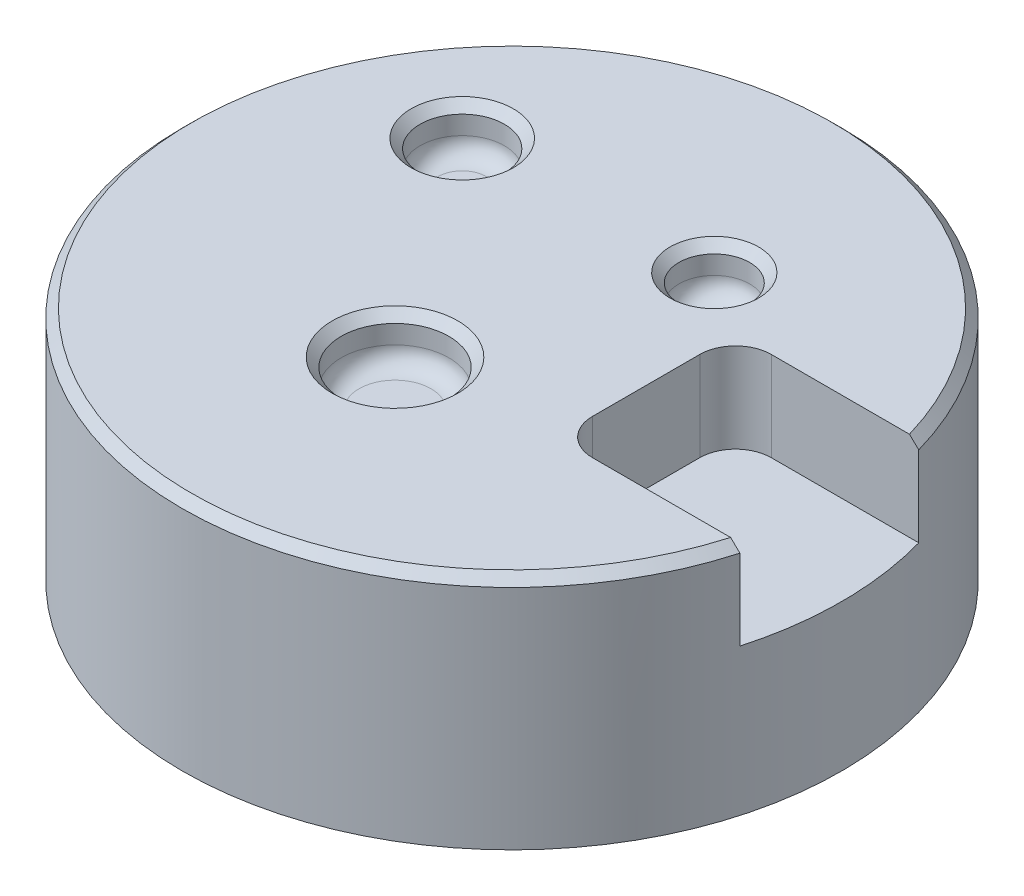
from build123d import *

# Parameters (mm, degrees)
SKETCH1_R           = 36.871673704
BOSS_EXTRUDE1_DEPTH = 26.416
SKETCH2_R           = 4.719401224
SKETCH2_R_2         = 3.956193561
SKETCH2_R_3         = 6.025487418
CUT_EXTRUDE1_DEPTH  = 5.08
CHAMFER1_SIZE       = 1
SKETCH4_W           = 30
SKETCH4_H           = 20
CUT_EXTRUDE2_DEPTH  = 10
FILLET1_R           = 4
FILLET3_R           = 2
CHAMFER3_SIZE       = 1


with BuildPart() as part:
    # Sketch1 → Boss-Extrude1 (new body)
    with BuildSketch(Plane(origin=(0, 0, 0), x_dir=(1, 0, 0), z_dir=(0, 1, 0))):
        with Locations(Location((0, 0, 0), (0, 0, 270))):  # turned: the seam where the file's is
            Circle(SKETCH1_R)
    extrude(amount=BOSS_EXTRUDE1_DEPTH)

    # Sketch2 → Cut-Extrude1 (cut)
    with BuildSketch(Plane(origin=(0, 26.416, 0), x_dir=(1, 0, 0), z_dir=(0, 1, 0))):
        with Locations(Location((-19.22121176, 13.655520005, 0), (0, 0, 270))):  # turned: the seam where the file's is
            Circle(SKETCH2_R)
        with Locations(Location((7.876648873, 14.748238638, 0), (0, 0, 270))):  # turned: the seam where the file's is
            Circle(SKETCH2_R_2)
        with Locations(Location((-1.786448021, -11.295248686, 0), (0, 0, 270))):  # turned: the seam where the file's is
            Circle(SKETCH2_R_3)
    extrude(amount=-CUT_EXTRUDE1_DEPTH, mode=Mode.SUBTRACT)

    # Chamfer1
    chamfer1_edges = [part.edges().sort_by_distance(p)[0] for p in [
        (0, 26.416, -36.871673704),
    ]]
    chamfer(chamfer1_edges, length=CHAMFER1_SIZE)

    # Sketch4 → Cut-Extrude2 (cut)
    with BuildSketch(Plane(origin=(0, 26.416, 0), x_dir=(1, 0, 0), z_dir=(0, 1, 0))):
        with Locations((30, 0)):
            Rectangle(SKETCH4_W, SKETCH4_H)
    extrude(amount=-CUT_EXTRUDE2_DEPTH, mode=Mode.SUBTRACT)

    # Fillet1
    fillet1_edges = [part.edges().sort_by_distance(p)[0] for p in [
        (15, 21.416, -10),
        (15, 21.416, 10),
    ]]
    fillet(fillet1_edges, radius=FILLET1_R)

    # Fillet3
    fillet3_edges = [part.edges().sort_by_distance(p)[0] for p in [
        (-1.786448021, 21.336, 5.269761268),
        (-19.22121176, 21.336, -18.374921228),
        (7.876648873, 21.336, -18.7044322),
    ]]
    fillet(fillet3_edges, radius=FILLET3_R)

    # Chamfer3
    chamfer3_edges = [part.edges().sort_by_distance(p)[0] for p in [
        (-1.786448021, 26.416, 5.269761268),
        (-19.22121176, 26.416, -18.374921228),
        (7.876648873, 26.416, -18.7044322),
    ]]
    chamfer(chamfer3_edges, length=CHAMFER3_SIZE)


solid = part.part
